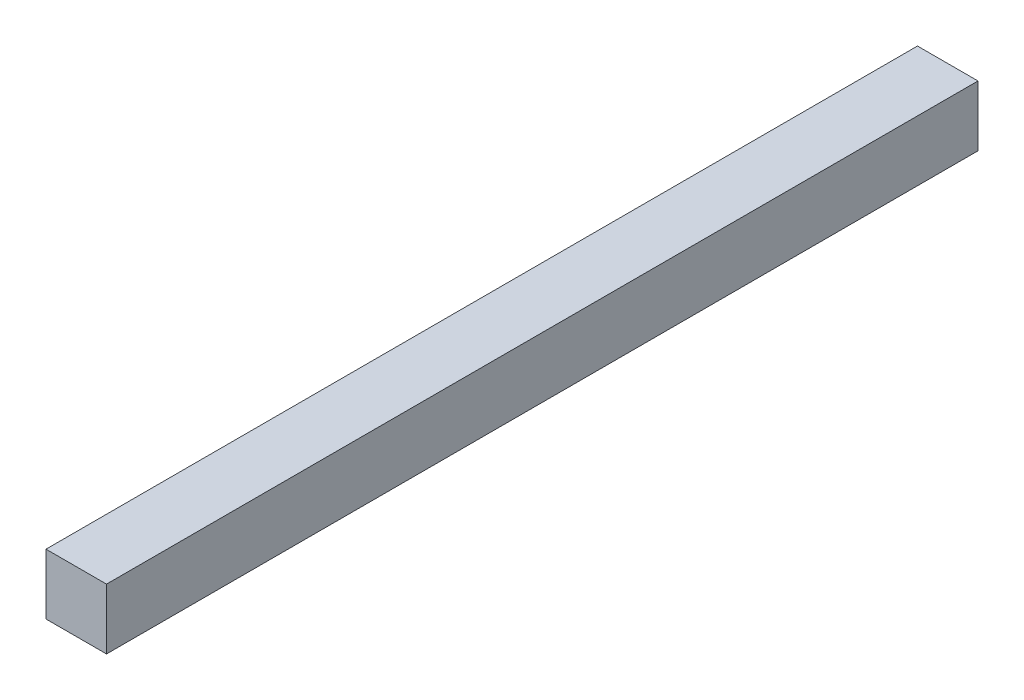
from build123d import *

# Parameters (mm, degrees)
SKETCH2_W           = 6.35
SKETCH2_H           = 6.35
BOSS_EXTRUDE1_DEPTH = 91.44


with BuildPart() as part:
    # Sketch2 → Boss-Extrude1 (new body)
    with BuildSketch(Plane.XY):
        with Locations((30.845408122, 10.681005057)):
            Rectangle(SKETCH2_W, SKETCH2_H)
    extrude(amount=BOSS_EXTRUDE1_DEPTH)


solid = part.part
